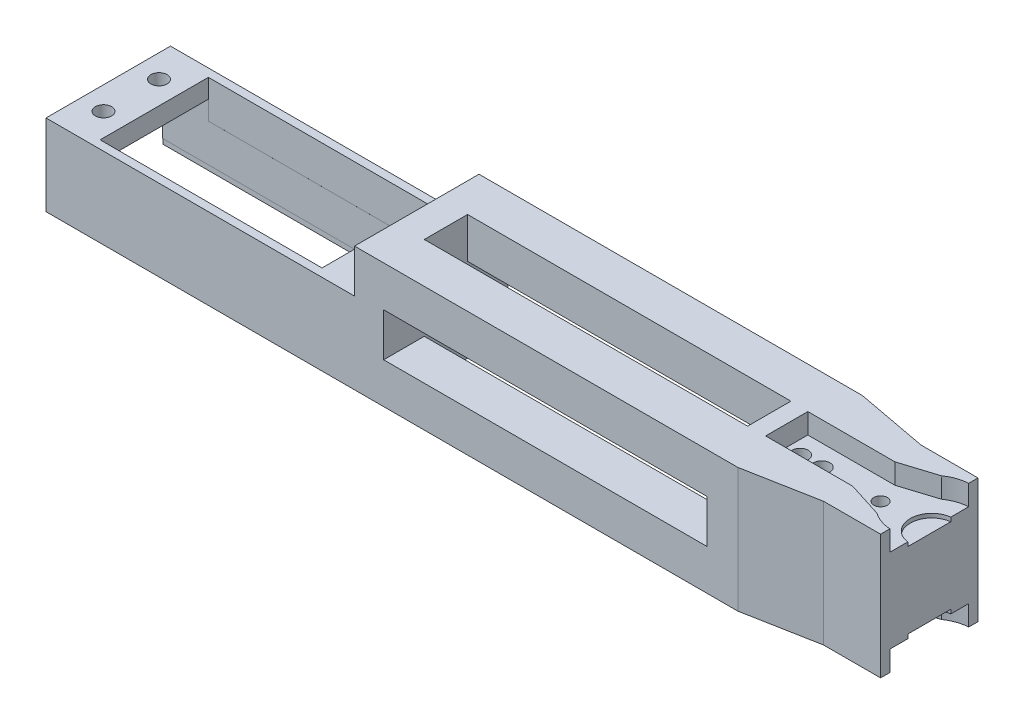
from build123d import *

# Parameters (mm, degrees)
BOSS_EXTRUDE1_DEPTH     = 11.5
SKETCH1_13_R            = 1.5
SKETCH1_13_R_2          = 1.25
BOSS_EXTRUDE2_DEPTH     = 7.75
BOSS_EXTRUDE3_DEPTH     = 7
SKETCH2_W               = 23
SKETCH2_H               = 23
BOSS_EXTRUDE4_DEPTH     = 120
CUT_EXTRUDE7_DEPTH      = 5
CUT_EXTRUDE7_DEPTH_BACK = 57
SKETCH9_W               = 19.998553098
SKETCH9_H               = 11.329894336
CUT_EXTRUDE8_START      = -8
SKETCH8_W               = 40.995866108
SKETCH8_H               = 19.999889565
SKETCH8_R               = 1.5
CUT_EXTRUDE8_DEPTH      = 20
SKETCH10_W              = 57.182789297
SKETCH10_H              = 20.379722455
CUT_EXTRUDE9_DEPTH      = 1
SKETCH11_W              = 59.739039785
SKETCH11_H              = 8
CUT_EXTRUDE10_DEPTH     = 40
SKETCH12_W              = 59.739039785
SKETCH12_H              = 8
CUT_EXTRUDE11_DEPTH     = 40
CUT_EXTRUDE12_DEPTH     = 57


with BuildPart() as part:
    # Sketch1 → Boss-Extrude1 (new, symmetric)
    with BuildSketch(Plane(origin=(0, 0, 0), x_dir=(1, 0, 0), z_dir=(0, 1, 0))):
        with BuildLine():
            Line((6.824314586, 7.284360201), (6.824314586, 9.00020274))
            Line((6.824314586, 9.00020274), (-3.690467309, 9.00020274))
            Line((-3.690467309, 9.00020274), (-17.038497557, 11.5))
            Line((-17.038497557, 11.5), (-24.867971487, 11.5))
            Line((-24.867971487, 11.5), (-24.867971487, -11.5))
            Line((-24.867971487, -11.5), (-17.038497557, -11.5))
            Line((-17.038497557, -11.5), (-3.690467309, -9.00020274))
            Line((-3.690467309, -9.00020274), (6.824314586, -9.00020274))
            Line((6.824314586, -9.00020274), (6.824314586, -7.284360201))
            ThreePointArc((6.824314586, -7.284360201), (4.861171432, -6.879883717), (3.082035449, -5.956732906))
            Line((3.082035449, -5.956732906), (-3.422402494, -3.9))
            Line((-3.422402494, -3.9), (-19.513448301, -3.9))
            Line((-19.513448301, -3.9), (-19.513448301, 3.9))
            Line((-19.513448301, 3.9), (-3.422402494, 3.9))
            Line((-3.422402494, 3.9), (3.082035449, 5.956732906))
            ThreePointArc((3.082035449, 5.956732906), (4.861171432, 6.879883717), (6.824314586, 7.284360201))
        make_face()
    extrude(amount=BOSS_EXTRUDE1_DEPTH, both=True)

    # Sketch1_13 → Boss-Extrude2 (add, symmetric)
    with BuildSketch(Plane(origin=(0, 0, 0), x_dir=(1, 0, 0), z_dir=(0, 1, 0))):
        with BuildLine():
            Line((6.824314586, 3.971385595), (6.824314586, 7.284360201))
            ThreePointArc((6.824314586, 7.284360201), (4.861171432, 6.879883717), (3.082035449, 5.956732906))
            Line((3.082035449, 5.956732906), (-3.422402494, 3.9))
            Line((-3.422402494, 3.9), (-19.513448301, 3.9))
            Line((-19.513448301, 3.9), (-19.513448301, -3.9))
            Line((-19.513448301, -3.9), (-3.422402494, -3.9))
            Line((-3.422402494, -3.9), (3.082035449, -5.956732906))
            ThreePointArc((3.082035449, -5.956732906), (4.861171432, -6.879883717), (6.824314586, -7.284360201))
            Line((6.824314586, -7.284360201), (6.824314586, -3.971385595))
            ThreePointArc((6.824314586, -3.971385595), (3.301909035, 0), (6.824314586, 3.971385595))
        make_face()
        with Locations((-17.038497557, 0)):
            Circle(SKETCH1_13_R, mode=Mode.SUBTRACT)
        with Locations((-13.038497557, 0)):
            Circle(SKETCH1_13_R, mode=Mode.SUBTRACT)
        with Locations((-2.172402494, 0)):
            Circle(SKETCH1_13_R_2, mode=Mode.SUBTRACT)
    extrude(amount=BOSS_EXTRUDE2_DEPTH, both=True)

    # Sketch1_14 → Boss-Extrude3 (add, symmetric)
    with BuildSketch(Plane(origin=(0, 0, 0), x_dir=(1, 0, 0), z_dir=(0, 1, 0))):
        with BuildLine():
            Line((6.824314586, -3.971385595), (6.824314586, 3.971385595))
            ThreePointArc((6.824314586, 3.971385595), (3.301909035, 0), (6.824314586, -3.971385595))
        make_face()
    extrude(amount=BOSS_EXTRUDE3_DEPTH, both=True)

    # Sketch2 → Boss-Extrude4 (add)
    with BuildSketch(Plane.ZY.offset(24.867971487)):
        Rectangle(SKETCH2_W, SKETCH2_H)
    extrude(amount=BOSS_EXTRUDE4_DEPTH)

    # Sketch9 → Cut-Extrude7 (cut, two sides: drawn at the far end of the back side and taken through both)
    with BuildSketch(Plane.ZY.offset(144.867971487).offset(-CUT_EXTRUDE7_DEPTH_BACK)):
        with Locations((0.000723451, -5.664947168)):
            Rectangle(SKETCH9_W, SKETCH9_H)
    extrude(amount=CUT_EXTRUDE7_DEPTH + CUT_EXTRUDE7_DEPTH_BACK, mode=Mode.SUBTRACT)

    # Sketch8 → Cut-Extrude8 (cut)
    with BuildSketch(Plane.XZ.offset(11.5).offset(CUT_EXTRUDE8_START)):
        with Locations((-115.870038433, 5.5217e-05)):
            Rectangle(SKETCH8_W, SKETCH8_H)
        with Locations((-140.617971487, 5.125)):
            Circle(SKETCH8_R)
        with Locations((-140.617971487, -5.125)):
            Circle(SKETCH8_R)
        with Locations((-91.122105379, 5.125027608)):
            Circle(SKETCH8_R)
        with Locations((-91.121972212, -5.124917175)):
            Circle(SKETCH8_R)
    extrude(amount=-CUT_EXTRUDE8_DEPTH, mode=Mode.SUBTRACT)

    # Sketch10 → Cut-Extrude9 (cut)
    with BuildSketch(Plane.XZ.offset(11.5)):
        with Locations((-116.276576839, 0.092053876)):
            Rectangle(SKETCH10_W, SKETCH10_H)
    extrude(amount=-CUT_EXTRUDE9_DEPTH, mode=Mode.SUBTRACT)

    # Sketch11 → Cut-Extrude10 (cut)
    with BuildSketch(Plane(origin=(0, 11.5, 0), x_dir=(1, 0, 0), z_dir=(0, 1, 0))):
        with Locations((-52.611089146, 0)):
            Rectangle(SKETCH11_W, SKETCH11_H)
    extrude(amount=-CUT_EXTRUDE10_DEPTH, mode=Mode.SUBTRACT)

    # Sketch12 → Cut-Extrude11 (cut)
    with BuildSketch(Plane(origin=(0, 0, -11.5), x_dir=(-1, 0, 0), z_dir=(0, 0, -1))):
        with Locations((52.611089146, 0)):
            Rectangle(SKETCH12_W, SKETCH12_H)
    extrude(amount=-CUT_EXTRUDE11_DEPTH, mode=Mode.SUBTRACT)

    # Sketch9_12 → Cut-Extrude12 (cut)
    with BuildSketch(Plane.ZY.offset(144.867971487)):
        Polygon((10, 3.5), (11.5, 3.5), (11.5, 3.545517382), (11.5, 11.5), (10, 11.5), (-9.999842993, 11.5), (-11.5, 11.5), (-11.5, 3.5), (-10, 3.5), align=None)
    extrude(amount=-CUT_EXTRUDE12_DEPTH, mode=Mode.SUBTRACT)


solid = part.part
